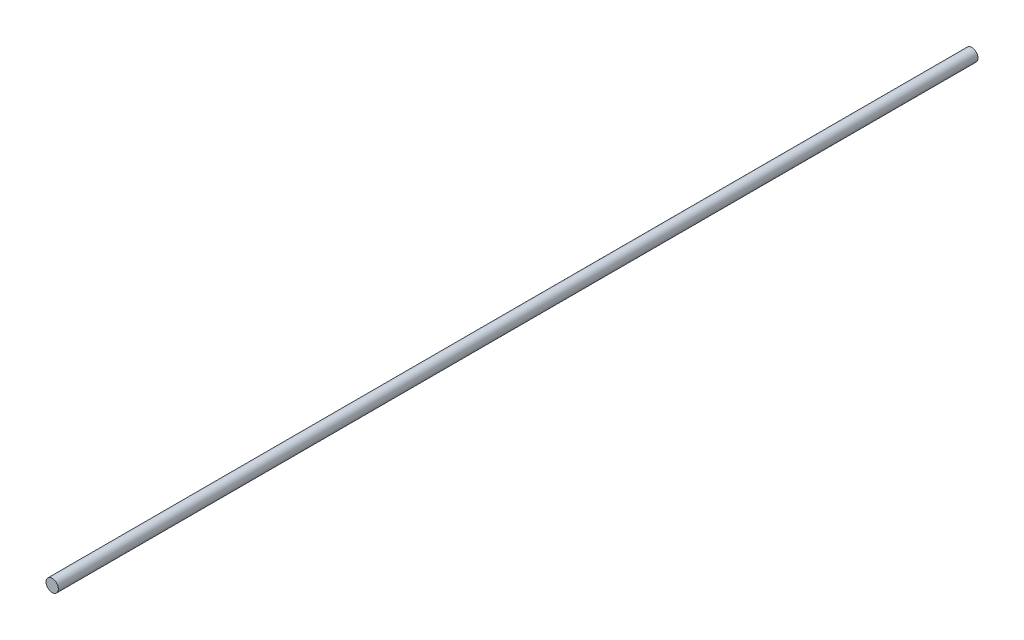
from build123d import *

# Parameters (mm, degrees)
SKETCH1_R           = 3.175
BOSS_EXTRUDE1_DEPTH = 472.435


with BuildPart() as part:
    # Sketch1 → Boss-Extrude1 (new body)
    with BuildSketch(Plane.XY):
        Circle(SKETCH1_R)
    extrude(amount=BOSS_EXTRUDE1_DEPTH)


solid = part.part
